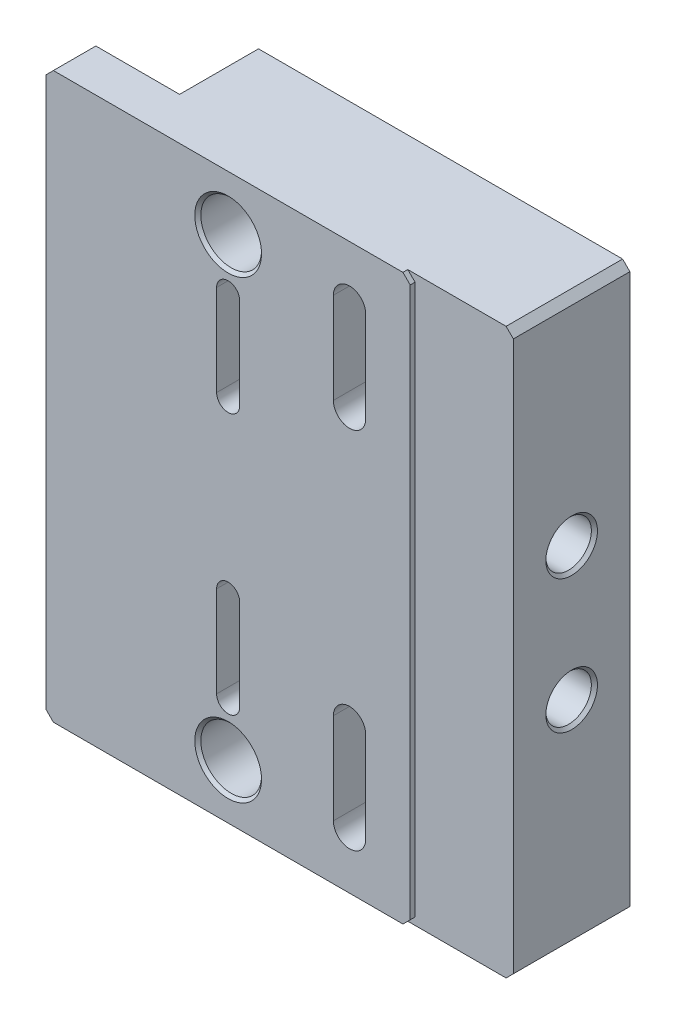
from build123d import *

# Parameters (mm, degrees)
BOSS_EXTRUDE1_DEPTH              = 25.4
F_1_2_13_TAPPED_HOLE1_AT_2_COUNT = 2
F_1_2_13_TAPPED_HOLE1_AT_2_PITCH = 95.25
CUT_EXTRUDE1_DEPTH               = 5.842
CUT_EXTRUDE2_DEPTH               = 1.016
F_3_8_16_TAPPED_HOLE1_AT_2_COUNT = 2
F_3_8_16_TAPPED_HOLE1_AT_2_PITCH = 27.94
CUT_EXTRUDE3_DEPTH               = 26.4
CUT_EXTRUDE4_DEPTH               = 10.668
SKETCH15_W                       = 19.05
SKETCH15_H                       = 16.51
CUT_EXTRUDE5_DEPTH               = 119.11


with BuildPart() as part:
    # Sketch6 → Boss-Extrude1 (new body)
    with BuildSketch(Plane.XY):
        Polygon((-36.576, 59.055), (57.15, 59.055), (58.674, 57.531), (58.674, -57.531), (57.15, -59.055), (-36.576, -59.055), (-38.1, -57.531), (-38.1, 57.531), align=None)
    extrude(amount=-BOSS_EXTRUDE1_DEPTH)

    # Sketch7 → 1/2-13 Tapped Hole1 (revolve, cut)
    with BuildSketch(Plane(origin=(0, 47.625, -25.4), x_dir=(0, 1, 0), z_dir=(1, 0, 0))):
        Polygon((0, 0), (0, 25.4), (6.985, 25.4), (6.35, 24.765), (6.35, 0.635), (6.985, 0), align=None)
    f_1_2_13_tapped_hole1 = revolve(axis=Axis((0, 47.625, -31.75), (0, 0, 1)), mode=Mode.SUBTRACT)

    # 1/2-13 Tapped Hole1 at 2: 1/2-13 Tapped Hole1 ×2
    with Locations(*[(0, -i * F_1_2_13_TAPPED_HOLE1_AT_2_PITCH, 0) for i in range(1, F_1_2_13_TAPPED_HOLE1_AT_2_COUNT)]):
        add(f_1_2_13_tapped_hole1, mode=Mode.SUBTRACT)

    # Sketch9 → Cut-Extrude1 (cut)
    with BuildSketch(Plane(origin=(0, 0, 0), x_dir=(-1, 0, 0), z_dir=(0, 0, -1))):
        with BuildLine():
            Line((-2.413, 17.78), (-2.413, 36.83))
            ThreePointArc((-2.413, 36.83), (0, 39.243), (2.413, 36.83))
            Line((2.413, 36.83), (2.413, 17.78))
            ThreePointArc((2.413, 17.78), (0, 15.367), (-2.413, 17.78))
        make_face()
        with BuildLine():
            Line((2.413, -17.78), (2.413, -36.83))
            ThreePointArc((2.413, -36.83), (0, -39.243), (-2.413, -36.83))
            Line((-2.413, -36.83), (-2.413, -17.78))
            ThreePointArc((-2.413, -17.78), (0, -15.367), (2.413, -17.78))
        make_face()
    extrude(amount=CUT_EXTRUDE1_DEPTH, mode=Mode.SUBTRACT)

    # Sketch12 → Cut-Extrude2 (cut)
    with BuildSketch(Plane.XY):
        Polygon((38.1, 57.531), (38.1, -57.531), (36.576, -59.055), (57.15, -59.055), (58.674, -57.531), (58.674, 57.531), (57.15, 59.055), (36.576, 59.055), align=None)
    extrude(amount=-CUT_EXTRUDE2_DEPTH, mode=Mode.SUBTRACT)

    # Sketch10 → 3/8-16 Tapped Hole1 (revolve, cut)
    with BuildSketch(Plane(origin=(58.674, 13.97, -13.208), x_dir=(0, 0, -1), z_dir=(0, 1, 0))):
        Polygon((0, 0), (0, 27.987865582), (3.96875, 25.6032), (3.96875, 21.59), (4.7625, 21.59), (4.7625, 0.635), (5.3975, 0), align=None)
    f_3_8_16_tapped_hole1 = revolve(axis=Axis((65.024, 13.97, -13.208), (-1, 0, 0)), mode=Mode.SUBTRACT)

    # 3/8-16 Tapped Hole1 at 2: 3/8-16 Tapped Hole1 ×2
    with Locations(*[(0, -i * F_3_8_16_TAPPED_HOLE1_AT_2_PITCH, 0) for i in range(1, F_3_8_16_TAPPED_HOLE1_AT_2_COUNT)]):
        add(f_3_8_16_tapped_hole1, mode=Mode.SUBTRACT)

    # Sketch13 → Cut-Extrude3 (cut, through all)
    with BuildSketch(Plane.XY):
        with BuildLine():
            Line((28.7782, 47.625), (28.7782, 28.575))
            ThreePointArc((28.7782, 28.575), (25.4, 25.1968), (22.0218, 28.575))
            Line((22.0218, 28.575), (22.0218, 47.625))
            ThreePointArc((22.0218, 47.625), (25.4, 51.0032), (28.7782, 47.625))
        make_face()
        with BuildLine():
            Line((28.7782, -28.575), (28.7782, -47.625))
            ThreePointArc((28.7782, -47.625), (25.4, -51.0032), (22.0218, -47.625))
            Line((22.0218, -47.625), (22.0218, -28.575))
            ThreePointArc((22.0218, -28.575), (25.4, -25.1968), (28.7782, -28.575))
        make_face()
    extrude(amount=-CUT_EXTRUDE3_DEPTH, mode=Mode.SUBTRACT)

    # Sketch14 → Cut-Extrude4 (cut)
    with BuildSketch(Plane.XY.offset(-25.4)):
        with BuildLine():
            Line((32.54375, 47.625), (32.54375, 28.575))
            ThreePointArc((32.54375, 28.575), (25.4, 21.43125), (18.25625, 28.575))
            Line((18.25625, 28.575), (18.25625, 47.625))
            ThreePointArc((18.25625, 47.625), (25.4, 54.76875), (32.54375, 47.625))
        make_face()
        with BuildLine():
            Line((32.54375, -28.575), (32.54375, -47.625))
            ThreePointArc((32.54375, -47.625), (25.4, -54.76875), (18.25625, -47.625))
            Line((18.25625, -47.625), (18.25625, -28.575))
            ThreePointArc((18.25625, -28.575), (25.4, -21.43125), (32.54375, -28.575))
        make_face()
    extrude(amount=CUT_EXTRUDE4_DEPTH, mode=Mode.SUBTRACT)

    # Sketch15 → Cut-Extrude5 (cut, through all)
    with BuildSketch(Plane.XZ.offset(59.055)):
        with Locations((-28.575, -17.145)):
            Rectangle(SKETCH15_W, SKETCH15_H)
    extrude(amount=-CUT_EXTRUDE5_DEPTH, mode=Mode.SUBTRACT)


solid = part.part
